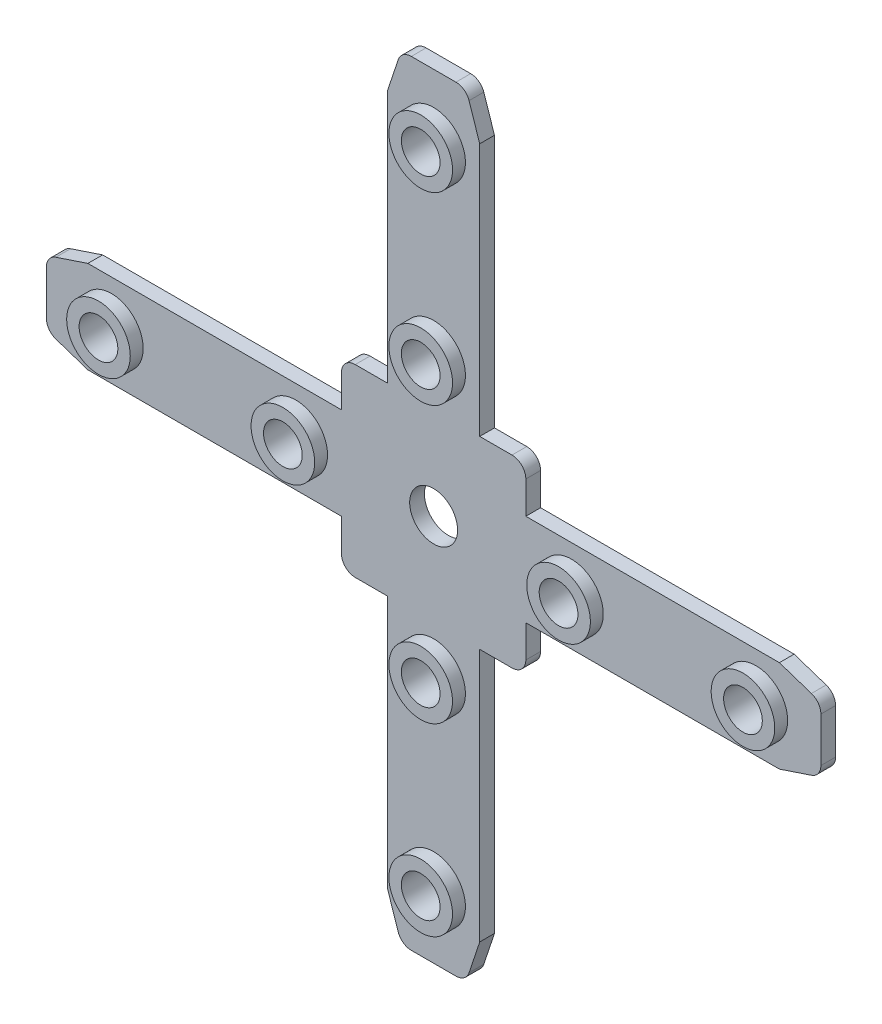
from build123d import *

# Parameters (mm, degrees)
SKETCH1_R             = 2.6
BOSS_EXTRUDE1_DEPTH   = 1.6
SKETCH2_R             = 3.45
BOSS_EXTRUDE2_DEPTH   = 1.4
M5X0_8_TAPPED_HOLE1_D = 4.2


with BuildPart() as part:
    # Sketch1 → Boss-Extrude1 (new body)
    with BuildSketch(Plane.XY):
        with BuildLine():
            Line((-10, -8.5), (-10, -5))
            Line((-10, -5), (-37.5, -5))
            Line((-37.5, -5), (-40.974341649, -3.841886117))
            ThreePointArc((-40.974341649, -3.841886117), (-41.716863278, -3.295926597), (-42, -2.41886117))
            Line((-42, -2.41886117), (-42, 2.41886117))
            ThreePointArc((-42, 2.41886117), (-41.716863278, 3.295926597), (-40.974341649, 3.841886117))
            Line((-40.974341649, 3.841886117), (-37.5, 5))
            Line((-37.5, 5), (-10, 5))
            Line((-10, 5), (-10, 8.5))
            ThreePointArc((-10, 8.5), (-9.560660172, 9.560660172), (-8.5, 10))
            Line((-8.5, 10), (-5, 10))
            Line((-5, 10), (-5, 37.485))
            Line((-5, 37.485), (-3.841886117, 40.959341649))
            ThreePointArc((-3.841886117, 40.959341649), (-3.295926597, 41.701863278), (-2.41886117, 41.985))
            Line((-2.41886117, 41.985), (2.41886117, 41.985))
            ThreePointArc((2.41886117, 41.985), (3.295926597, 41.701863278), (3.841886117, 40.959341649))
            Line((3.841886117, 40.959341649), (5, 37.485))
            Line((5, 37.485), (5, 10))
            Line((5, 10), (8.5, 10))
            ThreePointArc((8.5, 10), (9.560660172, 9.560660172), (10, 8.5))
            Line((10, 8.5), (10, 5))
            Line((10, 5), (37.5, 5))
            Line((37.5, 5), (40.974341649, 3.841886117))
            ThreePointArc((40.974341649, 3.841886117), (41.716863278, 3.295926597), (42, 2.41886117))
            Line((42, 2.41886117), (42, -2.41886117))
            ThreePointArc((42, -2.41886117), (41.716863278, -3.295926597), (40.974341649, -3.841886117))
            Line((40.974341649, -3.841886117), (37.5, -5))
            Line((37.5, -5), (10, -5))
            Line((10, -5), (10, -8.5))
            ThreePointArc((10, -8.5), (9.560660172, -9.560660172), (8.5, -10))
            Line((8.5, -10), (5, -10))
            Line((5, -10), (5, -37.485))
            Line((5, -37.485), (3.841886117, -40.959341649))
            ThreePointArc((3.841886117, -40.959341649), (3.295926597, -41.701863278), (2.41886117, -41.985))
            Line((2.41886117, -41.985), (-2.41886117, -41.985))
            ThreePointArc((-2.41886117, -41.985), (-3.295926597, -41.701863278), (-3.841886117, -40.959341649))
            Line((-3.841886117, -40.959341649), (-5, -37.485))
            Line((-5, -37.485), (-5, -10))
            Line((-5, -10), (-8.5, -10))
            ThreePointArc((-8.5, -10), (-9.560660172, -9.560660172), (-10, -8.5))
        make_face()
        Circle(SKETCH1_R, mode=Mode.SUBTRACT)
    extrude(amount=BOSS_EXTRUDE1_DEPTH)

    # Sketch2 → Boss-Extrude2 (add)
    with BuildSketch(Plane.XY.offset(1.6)):
        with Locations((0, 14.95)):
            Circle(SKETCH2_R)
        with Locations((0, 34.95)):
            Circle(SKETCH2_R)
        with Locations((0, -14.95)):
            Circle(SKETCH2_R)
        with Locations((0, -34.95)):
            Circle(SKETCH2_R)
        with Locations((-14.95, 0)):
            Circle(SKETCH2_R)
        with Locations((-34.95, 0)):
            Circle(SKETCH2_R)
        with Locations((14.95, 0)):
            Circle(SKETCH2_R)
        with Locations((34.95, 0)):
            Circle(SKETCH2_R)
    extrude(amount=BOSS_EXTRUDE2_DEPTH)

    # M5x0.8 Tapped Hole1 (through all)
    with Locations(Plane.XY.offset(3)):
        with Locations((0, 34.95), (0, 14.95), (0, -14.95), (0, -34.95), (-14.95, 0), (-34.95, 0), (14.95, 0), (34.95, 0)):
            Hole(M5X0_8_TAPPED_HOLE1_D / 2)


solid = part.part
